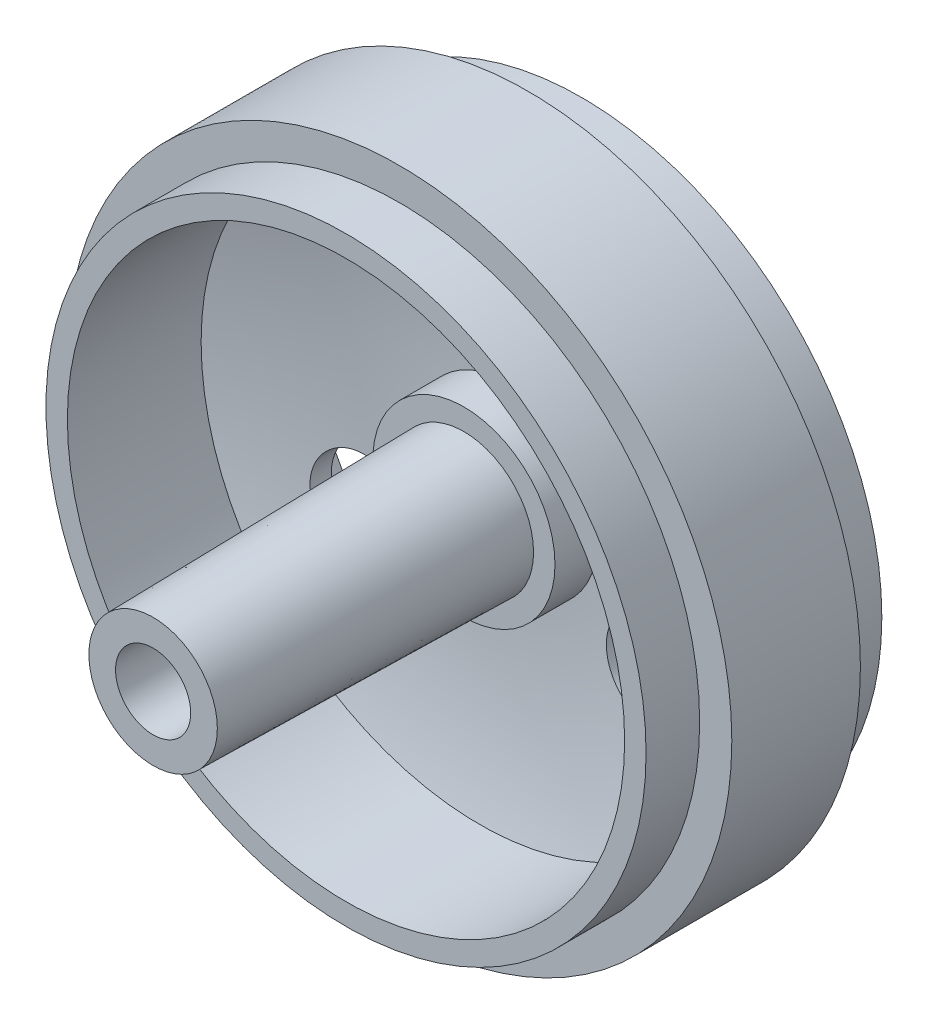
from build123d import *

# Parameters (mm, degrees)
SKETCH4_R                     = 3.25
SKETCH4_R_2                   = 1.5
BOSS_EXTRUDE1_DEPTH           = 14.5
BOSS_EXTRUDE1_TAPER           = 1
BOSS_EXTRUDE1_OTHER_WAY_DEPTH = 1
SKETCH5_R                     = 2
CUT_EXTRUDE1_DEPTH            = 14.5


with BuildPart() as part:
    # Sketch3 → Revolve1 (revolve)
    with BuildSketch(Plane(origin=(0, 0, 0), x_dir=(0, 0, -1), z_dir=(1, 0, 0))):
        with BuildLine():
            Line((-5.5, 13), (0.74, 13))
            ThreePointArc((0.74, 13), (1.672291774, 8.668530015), (2, 4.25))
            Line((2, 4.25), (0, 4.25))
            Line((0, 4.25), (0, 3.25))
            Line((0, 3.25), (5.5, 3.25))
            Line((5.5, 3.25), (5.5, 4.25))
            Line((5.5, 4.25), (3, 4.25))
            ThreePointArc((3, 4.25), (2.672291774, 8.668530015), (1.74, 13))
            Line((1.74, 13), (5.5, 13))
            Line((5.5, 13), (5.5, 14))
            Line((5.5, 14), (3, 14))
            Line((3, 14), (3, 15.5))
            Line((3, 15.5), (-3, 15.5))
            Line((-3, 15.5), (-3, 14))
            Line((-3, 14), (-5.5, 14))
            Line((-5.5, 14), (-5.5, 13))
        make_face()
    revolve(axis=Axis((0, 0, 77.747530796), (0, 0, -1)))

    # Sketch4 → Boss-Extrude1 (add)
    with BuildSketch(Plane.XY):
        Circle(SKETCH4_R)
        Circle(SKETCH4_R_2, mode=Mode.SUBTRACT)
    extrude(amount=BOSS_EXTRUDE1_DEPTH, taper=BOSS_EXTRUDE1_TAPER)

    # Sketch4 → Boss-Extrude1 other way (add)
    with BuildSketch(Plane.XY):
        Circle(SKETCH4_R)
        Circle(SKETCH4_R_2, mode=Mode.SUBTRACT)
    extrude(amount=-BOSS_EXTRUDE1_OTHER_WAY_DEPTH)

    # Sketch5 → Cut-Extrude1 (cut)
    with BuildSketch(Plane(origin=(0, 0, -5.5), x_dir=(-1, 0, 0), z_dir=(0, 0, -1))):
        with Locations((0, 7.75)):
            Circle(SKETCH5_R)
        with Locations((6.711696879, -3.875)):
            Circle(SKETCH5_R)
        with Locations((-6.711696879, -3.875)):
            Circle(SKETCH5_R)
    extrude(amount=-CUT_EXTRUDE1_DEPTH, mode=Mode.SUBTRACT)


solid = part.part
